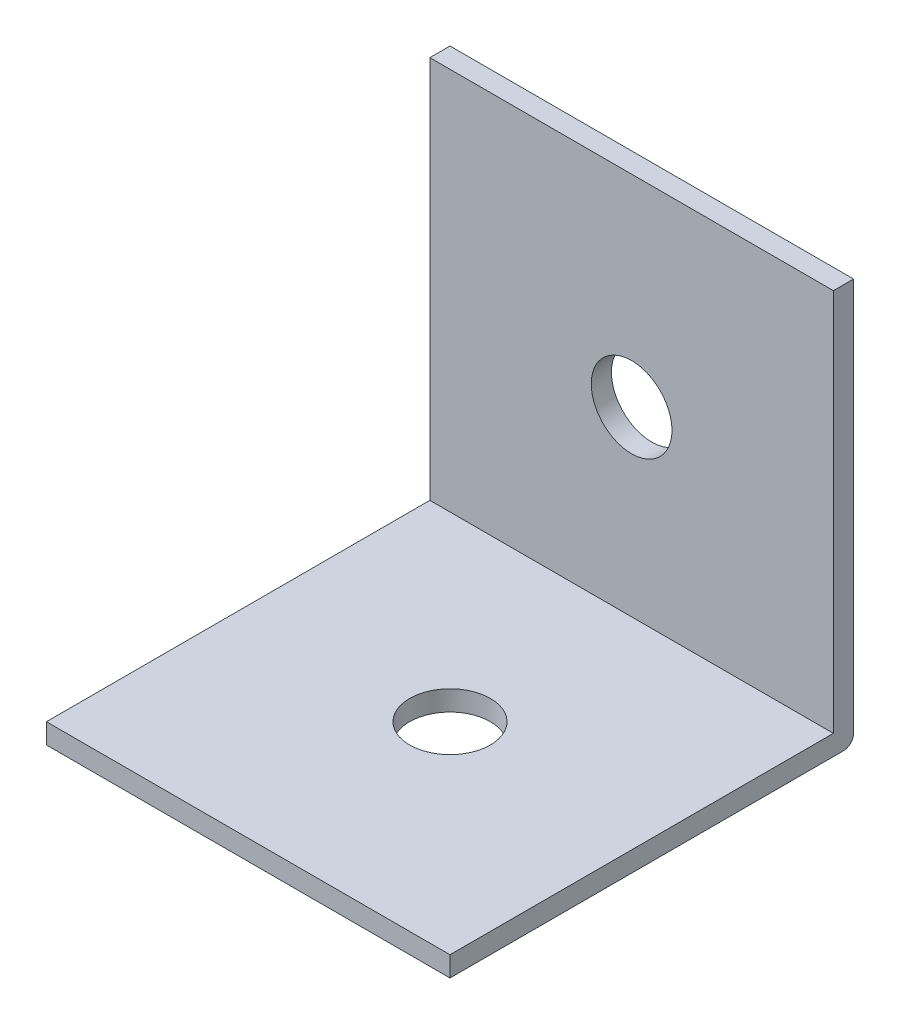
from build123d import *

# Parameters (mm, degrees)
SKETCH1_W           = 20
SKETCH1_H           = 20
BOSS_EXTRUDE1_DEPTH = 10
SKETCH3_W           = 19
SKETCH3_H           = 19
CUT_EXTRUDE1_DEPTH  = 20
FILLET1_R           = 0.5
SKETCH4_R           = 2
CUT_EXTRUDE2_DEPTH  = 2
SKETCH5_R           = 2
CUT_EXTRUDE3_DEPTH  = 2


with BuildPart() as part:
    # Sketch1 → Boss-Extrude1 (new body, symmetric)
    with BuildSketch(Plane(origin=(0, 0, 0), x_dir=(0, 0, -1), z_dir=(1, 0, 0))):
        with Locations((-10, 10)):
            Rectangle(SKETCH1_W, SKETCH1_H)
    extrude(amount=BOSS_EXTRUDE1_DEPTH, both=True)

    # Sketch3 → Cut-Extrude1 (cut)
    with BuildSketch(Plane(origin=(10, 0, 0), x_dir=(0, 0, -1), z_dir=(1, 0, 0))):
        with Locations((-10.5, 10.5)):
            Rectangle(SKETCH3_W, SKETCH3_H)
    extrude(amount=-CUT_EXTRUDE1_DEPTH, mode=Mode.SUBTRACT)

    # Fillet1
    fillet1_edges = [part.edges().sort_by_distance(p)[0] for p in [
        (0, 0, 0),
    ]]
    fillet(fillet1_edges, radius=FILLET1_R)

    # Sketch4 → Cut-Extrude2 (cut)
    with BuildSketch(Plane(origin=(0, 0, 0), x_dir=(-1, 0, 0), z_dir=(0, 0, -1))):
        with Locations((0, 10)):
            Circle(SKETCH4_R)
    extrude(amount=-CUT_EXTRUDE2_DEPTH, mode=Mode.SUBTRACT)

    # Sketch5 → Cut-Extrude3 (cut)
    with BuildSketch(Plane.XZ):
        with Locations((0, 10)):
            Circle(SKETCH5_R)
    extrude(amount=-CUT_EXTRUDE3_DEPTH, mode=Mode.SUBTRACT)


solid = part.part
